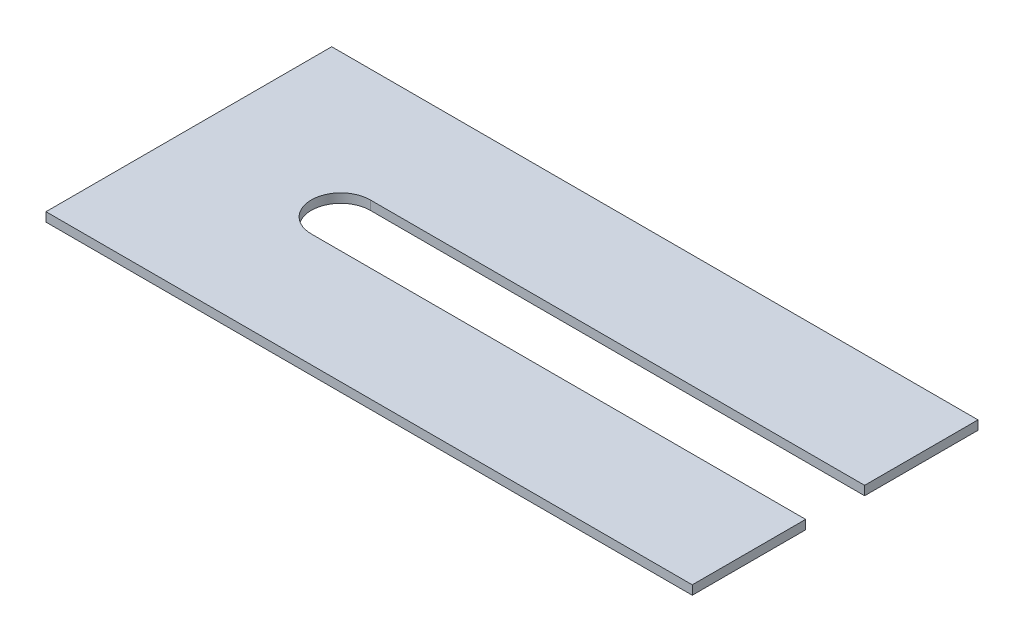
from build123d import *

# Parameters (mm, degrees)
BOSS_EXTRUDE1_DEPTH = 1


with BuildPart() as part:
    # Sketch1 → Boss-Extrude1 (new body)
    with BuildSketch(Plane(origin=(0, 0, 0), x_dir=(1, 0, 0), z_dir=(0, 1, 0))):
        with BuildLine():
            Line((0, 31.5), (0, 0))
            Line((0, 0), (71.25, 0))
            Line((71.25, 0), (71.25, 12.5))
            Line((71.25, 12.5), (16.75, 12.5))
            ThreePointArc((16.75, 12.5), (13.5, 15.75), (16.75, 19))
            Line((16.75, 19), (71.25, 19))
            Line((71.25, 19), (71.25, 31.5))
            Line((71.25, 31.5), (0, 31.5))
        make_face()
    extrude(amount=BOSS_EXTRUDE1_DEPTH)


solid = part.part
